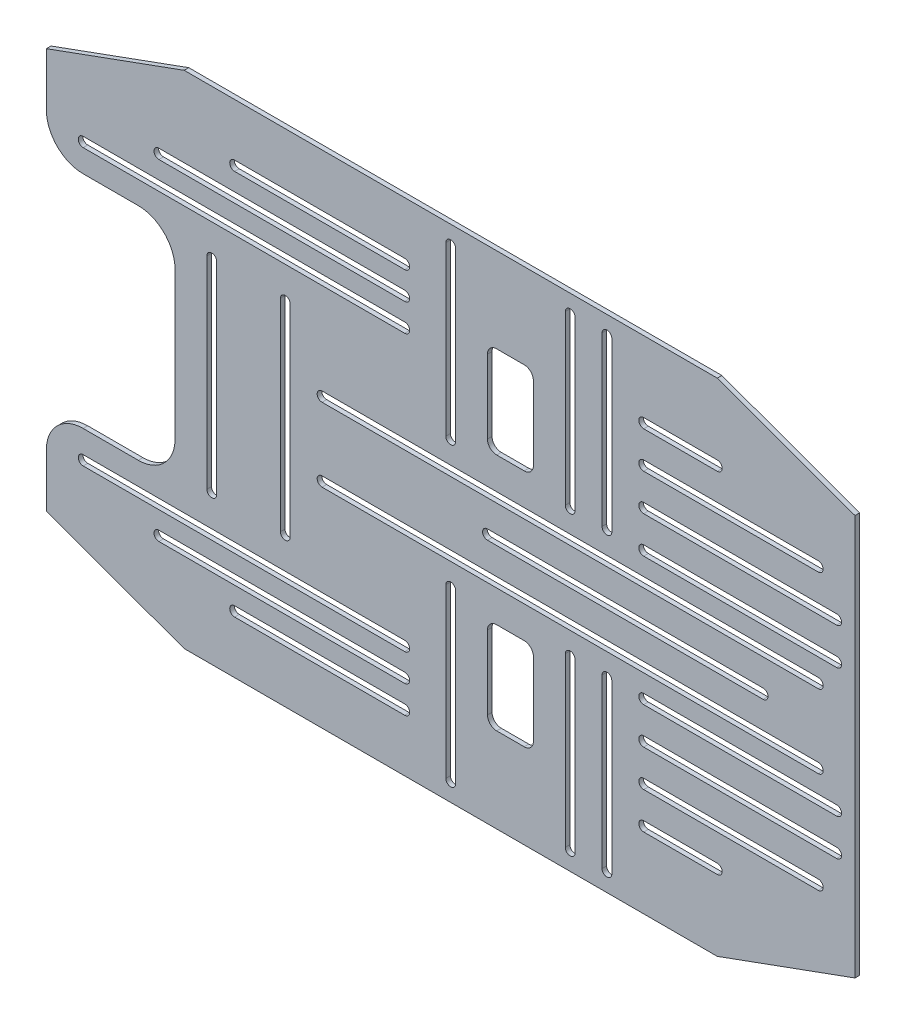
from build123d import *

# Parameters (mm, degrees)
BOSS_EXTRUDE1_DEPTH = 3.175
FILLET3_R           = 25.4
CUT_EXTRUDE3_DEPTH  = 4.175
SCALE1_SCALE        = 0.35


with BuildPart() as part:
    # Sketch1 → Boss-Extrude1 (new body)
    with BuildSketch(Plane.XY):
        Polygon((-279.4, 138.38935405), (-184.214073546, 173.034198), (184.214073546, 173.034198), (279.4, 138.38935405), (279.4, -138.38935405), (184.214073546, -173.034198), (-184.214073546, -173.034198), (-279.4, -138.38935405), (-279.4, -76.2), (-190.5, -76.2), (-190.5, 76.2), (-279.4, 76.2), align=None)
    extrude(amount=BOSS_EXTRUDE1_DEPTH)

    # Fillet3
    fillet3_edges = [part.edges().sort_by_distance(p)[0] for p in [
        (-279.4, -76.2, 1.5875),
        (-190.5, -76.2, 1.5875),
        (-190.5, 76.2, 1.5875),
        (-279.4, 76.2, 1.5875),
    ]]
    fillet(fillet3_edges, radius=FILLET3_R)

    # Sketch4 → Cut-Extrude3 (cut, through all)
    with BuildSketch(Plane.XY.offset(3.175)):
        with BuildLine():
            Line((-254, 98.6282), (-31.75, 98.6282))
            ThreePointArc((-31.75, 98.6282), (-28.3718, 95.25), (-31.75, 91.8718))
            Line((-31.75, 91.8718), (-254, 91.8718))
            ThreePointArc((-254, 91.8718), (-257.3782, 95.25), (-254, 98.6282))
        make_face()
        with BuildLine():
            Line((-201.660555159, 117.6782), (-31.75, 117.6782))
            ThreePointArc((-31.75, 117.6782), (-28.3718, 114.3), (-31.75, 110.9218))
            Line((-31.75, 110.9218), (-201.660555159, 110.9218))
            ThreePointArc((-201.660555159, 110.9218), (-205.038755159, 114.3), (-201.660555159, 117.6782))
        make_face()
        with BuildLine():
            Line((-149.321110319, 136.7282), (-31.75, 136.7282))
            ThreePointArc((-31.75, 136.7282), (-28.3718, 133.35), (-31.75, 129.9718))
            Line((-31.75, 129.9718), (-149.321110319, 129.9718))
            ThreePointArc((-149.321110319, 129.9718), (-152.699310319, 133.35), (-149.321110319, 136.7282))
        make_face()
        with BuildLine():
            Line((-161.7218, 69.85), (-161.7218, -69.85))
            ThreePointArc((-161.7218, -69.85), (-165.1, -73.2282), (-168.4782, -69.85))
            Line((-168.4782, -69.85), (-168.4782, 69.85))
            ThreePointArc((-168.4782, 69.85), (-165.1, 73.2282), (-161.7218, 69.85))
        make_face()
        with BuildLine():
            Line((-110.9218, 69.85), (-110.9218, -69.85))
            ThreePointArc((-110.9218, -69.85), (-114.3, -73.2282), (-117.6782, -69.85))
            Line((-117.6782, -69.85), (-117.6782, 69.85))
            ThreePointArc((-117.6782, 69.85), (-114.3, 73.2282), (-110.9218, 69.85))
        make_face()
        with BuildLine():
            Line((31.75, 114.3), (50.8, 114.3))
            ThreePointArc((50.8, 114.3), (55.290128061, 112.440128061), (57.15, 107.95))
            Line((57.15, 107.95), (57.15, 57.15))
            ThreePointArc((57.15, 57.15), (55.290128061, 52.659871939), (50.8, 50.8))
            Line((50.8, 50.8), (31.75, 50.8))
            ThreePointArc((31.75, 50.8), (27.259871939, 52.659871939), (25.4, 57.15))
            Line((25.4, 57.15), (25.4, 107.95))
            ThreePointArc((25.4, 107.95), (27.259871939, 112.440128061), (31.75, 114.3))
        make_face()
        with BuildLine():
            Line((3.3782, 160.334198), (3.3782, 44.45))
            ThreePointArc((3.3782, 44.45), (0, 41.0718), (-3.3782, 44.45))
            Line((-3.3782, 44.45), (-3.3782, 160.334198))
            ThreePointArc((-3.3782, 160.334198), (0, 163.712398), (3.3782, 160.334198))
        make_face()
        with BuildLine():
            Line((-88.9, 28.7782), (254, 28.7782))
            ThreePointArc((254, 28.7782), (257.3782, 25.4), (254, 22.0218))
            Line((254, 22.0218), (-88.9, 22.0218))
            ThreePointArc((-88.9, 22.0218), (-92.2782, 25.4), (-88.9, 28.7782))
        make_face()
        with BuildLine():
            Line((79.1718, 44.45), (79.1718, 160.334198))
            ThreePointArc((79.1718, 160.334198), (82.55, 163.712398), (85.9282, 160.334198))
            Line((85.9282, 160.334198), (85.9282, 44.45))
            ThreePointArc((85.9282, 44.45), (82.55, 41.0718), (79.1718, 44.45))
        make_face()
        with BuildLine():
            Line((111.3282, 160.334198), (111.3282, 44.45))
            ThreePointArc((111.3282, 44.45), (107.95, 41.0718), (104.5718, 44.45))
            Line((104.5718, 44.45), (104.5718, 160.334198))
            ThreePointArc((104.5718, 160.334198), (107.95, 163.712398), (111.3282, 160.334198))
        make_face()
        with BuildLine():
            Line((133.35, 124.0282), (184.214073546, 124.0282))
            ThreePointArc((184.214073546, 124.0282), (187.592273546, 120.65), (184.214073546, 117.2718))
            Line((184.214073546, 117.2718), (133.35, 117.2718))
            ThreePointArc((133.35, 117.2718), (129.9718, 120.65), (133.35, 124.0282))
        make_face()
        with BuildLine():
            Line((133.35, 98.6282), (254, 98.6282))
            ThreePointArc((254, 98.6282), (257.3782, 95.25), (254, 91.8718))
            Line((254, 91.8718), (133.35, 91.8718))
            ThreePointArc((133.35, 91.8718), (129.9718, 95.25), (133.35, 98.6282))
        make_face()
        with BuildLine():
            Line((133.35, 73.2282), (266.7, 73.2282))
            ThreePointArc((266.7, 73.2282), (270.0782, 69.85), (266.7, 66.4718))
            Line((266.7, 66.4718), (133.35, 66.4718))
            ThreePointArc((133.35, 66.4718), (129.9718, 69.85), (133.35, 73.2282))
        make_face()
        with BuildLine():
            Line((133.35, 47.8282), (266.7, 47.8282))
            ThreePointArc((266.7, 47.8282), (270.0782, 44.45), (266.7, 41.0718))
            Line((266.7, 41.0718), (133.35, 41.0718))
            ThreePointArc((133.35, 41.0718), (129.9718, 44.45), (133.35, 47.8282))
        make_face()
        with BuildLine():
            Line((-254, -98.6282), (-31.75, -98.6282))
            ThreePointArc((-31.75, -98.6282), (-28.3718, -95.25), (-31.75, -91.8718))
            Line((-31.75, -91.8718), (-254, -91.8718))
            ThreePointArc((-254, -91.8718), (-257.3782, -95.25), (-254, -98.6282))
        make_face()
        with BuildLine():
            Line((-201.660555159, -117.6782), (-31.75, -117.6782))
            ThreePointArc((-31.75, -117.6782), (-28.3718, -114.3), (-31.75, -110.9218))
            Line((-31.75, -110.9218), (-201.660555159, -110.9218))
            ThreePointArc((-201.660555159, -110.9218), (-205.038755159, -114.3), (-201.660555159, -117.6782))
        make_face()
        with BuildLine():
            Line((-149.321110319, -136.7282), (-31.75, -136.7282))
            ThreePointArc((-31.75, -136.7282), (-28.3718, -133.35), (-31.75, -129.9718))
            Line((-31.75, -129.9718), (-149.321110319, -129.9718))
            ThreePointArc((-149.321110319, -129.9718), (-152.699310319, -133.35), (-149.321110319, -136.7282))
        make_face()
        with BuildLine():
            Line((3.3782, -160.334198), (3.3782, -44.45))
            ThreePointArc((3.3782, -44.45), (0, -41.0718), (-3.3782, -44.45))
            Line((-3.3782, -44.45), (-3.3782, -160.334198))
            ThreePointArc((-3.3782, -160.334198), (0, -163.712398), (3.3782, -160.334198))
        make_face()
        with BuildLine():
            Line((-88.9, -28.7782), (254, -28.7782))
            ThreePointArc((254, -28.7782), (257.3782, -25.4), (254, -22.0218))
            Line((254, -22.0218), (-88.9, -22.0218))
            ThreePointArc((-88.9, -22.0218), (-92.2782, -25.4), (-88.9, -28.7782))
        make_face()
        with BuildLine():
            Line((79.1718, -44.45), (79.1718, -160.334198))
            ThreePointArc((79.1718, -160.334198), (82.55, -163.712398), (85.9282, -160.334198))
            Line((85.9282, -160.334198), (85.9282, -44.45))
            ThreePointArc((85.9282, -44.45), (82.55, -41.0718), (79.1718, -44.45))
        make_face()
        with BuildLine():
            Line((111.3282, -160.334198), (111.3282, -44.45))
            ThreePointArc((111.3282, -44.45), (107.95, -41.0718), (104.5718, -44.45))
            Line((104.5718, -44.45), (104.5718, -160.334198))
            ThreePointArc((104.5718, -160.334198), (107.95, -163.712398), (111.3282, -160.334198))
        make_face()
        with BuildLine():
            Line((133.35, -124.0282), (184.214073546, -124.0282))
            ThreePointArc((184.214073546, -124.0282), (187.592273546, -120.65), (184.214073546, -117.2718))
            Line((184.214073546, -117.2718), (133.35, -117.2718))
            ThreePointArc((133.35, -117.2718), (129.9718, -120.65), (133.35, -124.0282))
        make_face()
        with BuildLine():
            Line((133.35, -98.6282), (254, -98.6282))
            ThreePointArc((254, -98.6282), (257.3782, -95.25), (254, -91.8718))
            Line((254, -91.8718), (133.35, -91.8718))
            ThreePointArc((133.35, -91.8718), (129.9718, -95.25), (133.35, -98.6282))
        make_face()
        with BuildLine():
            Line((133.35, -73.2282), (266.7, -73.2282))
            ThreePointArc((266.7, -73.2282), (270.0782, -69.85), (266.7, -66.4718))
            Line((266.7, -66.4718), (133.35, -66.4718))
            ThreePointArc((133.35, -66.4718), (129.9718, -69.85), (133.35, -73.2282))
        make_face()
        with BuildLine():
            Line((133.35, -47.8282), (266.7, -47.8282))
            ThreePointArc((266.7, -47.8282), (270.0782, -44.45), (266.7, -41.0718))
            Line((266.7, -41.0718), (133.35, -41.0718))
            ThreePointArc((133.35, -41.0718), (129.9718, -44.45), (133.35, -47.8282))
        make_face()
        with BuildLine():
            Line((57.15, -107.95), (57.15, -57.15))
            ThreePointArc((57.15, -57.15), (55.290128061, -52.659871939), (50.8, -50.8))
            Line((50.8, -50.8), (31.75, -50.8))
            ThreePointArc((31.75, -50.8), (27.259871939, -52.659871939), (25.4, -57.15))
            Line((25.4, -57.15), (25.4, -107.95))
            ThreePointArc((25.4, -107.95), (27.259871939, -112.440128061), (31.75, -114.3))
            Line((31.75, -114.3), (50.8, -114.3))
            ThreePointArc((50.8, -114.3), (55.290128061, -112.440128061), (57.15, -107.95))
        make_face()
        with BuildLine():
            Line((25.4, 3.3782), (215.9, 3.3782))
            ThreePointArc((215.9, 3.3782), (219.2782, 0), (215.9, -3.3782))
            Line((215.9, -3.3782), (25.4, -3.3782))
            ThreePointArc((25.4, -3.3782), (22.0218, 0), (25.4, 3.3782))
        make_face()
    extrude(amount=-CUT_EXTRUDE3_DEPTH, mode=Mode.SUBTRACT)


with BuildPart() as part_1:
    # Scale1: scaled about (14.826143857, 0, 1.5875)
    add(part.part.scale(SCALE1_SCALE).moved(Location((9.636993507, 0, 1.031875))))


solid = part_1.part
